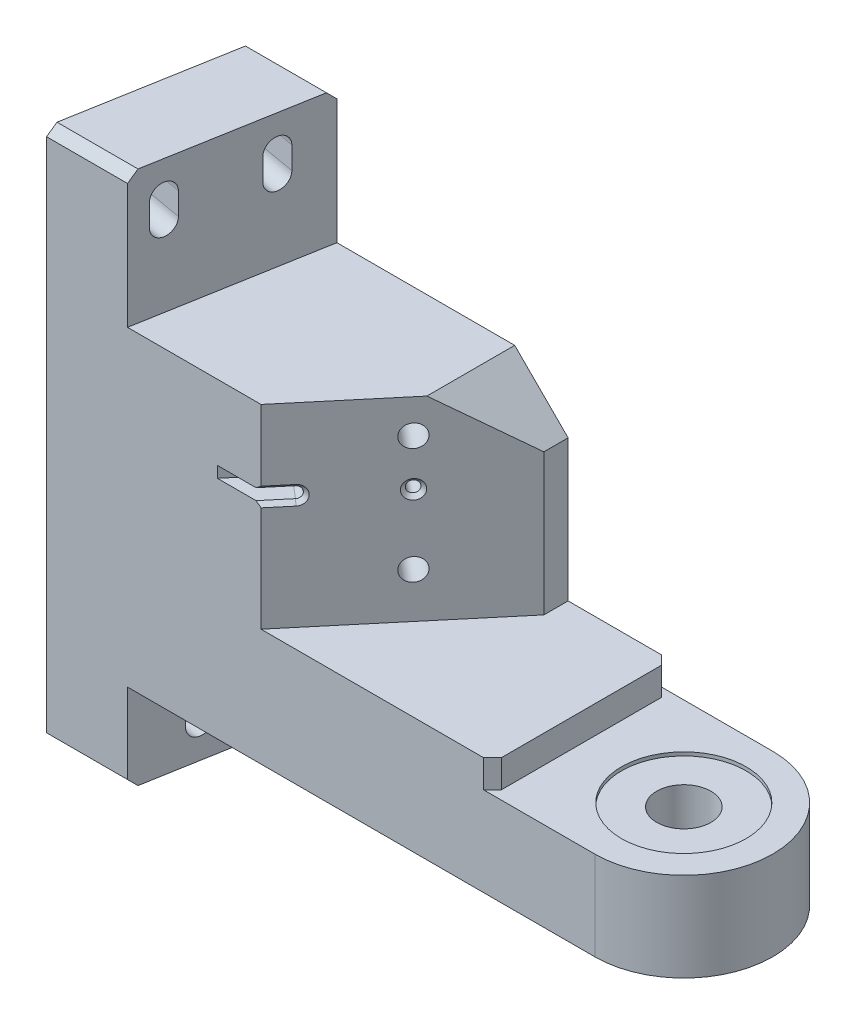
from build123d import *

# Parameters (mm, degrees)
SKETCH1_W                              = 181.864
SKETCH1_H                              = 50.8
EXTRUDE1_DEPTH                         = 152.4
EXTRUDE2_DEPTH                         = 153.4
EXTRUDE3_DEPTH                         = 38.1
EXTRUDE4_DEPTH                         = 55.5498
SKETCH5_W                              = 54.61
SKETCH5_H                              = 50.8
EXTRUDE5_DEPTH                         = 7.9502
EXTRUDE6_DEPTH                         = 25.4
EXTRUDE7_DEPTH                         = 32.584173829
LPATTERN1_COUNT                        = 2
LPATTERN1_PITCH                        = 127
LPATTERN1_COUNT_DIR2                   = 2
LPATTERN1_PITCH_DIR2                   = 27.94
F_1_4_20_TAPPED_HOLE1_D                = 5.1054
F_1_4_20_TAPPED_HOLE1_DEPTH            = 16.51
F_1_4_20_TAPPED_HOLE1_CBORE_D          = 6.35
F_1_4_20_TAPPED_HOLE1_CBORE_DEPTH      = 12.7
F_1_4_20_TAPPED_HOLE1_TIP              = 1.533816902
EXTRUDE9_DEPTH                         = 128
CHAMFER1_SIZE                          = 2.54
CHAMFER2_SIZE                          = 15.24
EXTRUDE10_DEPTH                        = 32.584173829
SCREW_THRU_HOLE_AND_CBORE_D            = 15.4686
SCREW_THRU_HOLE_AND_CBORE_CBORE_D      = 35.56
SCREW_THRU_HOLE_AND_CBORE_CBORE_DEPTH  = 1.016
F_1_8_0_125_DIAMETER_HOLE1_D           = 3.19024
F_1_8_0_125_DIAMETER_HOLE1_DEPTH       = 9.525
F_1_8_0_125_DIAMETER_HOLE1_CSINK_D     = 5.334
F_1_8_0_125_DIAMETER_HOLE1_CSINK_ANGLE = 90
F_1_8_0_125_DIAMETER_HOLE1_TIP         = 0.958444791
CUT_EXTRUDE1_DEPTH                     = 9.525
CHAMFER3_SIZE                          = 1.0795


with BuildPart() as part:
    # Sketch1 → Extrude1 (new body)
    with BuildSketch(Plane(origin=(0, 0, 0), x_dir=(1, 0, 0), z_dir=(0, 1, 0))):
        with Locations((-65.532, 0)):
            Rectangle(SKETCH1_W, SKETCH1_H)
    extrude(amount=EXTRUDE1_DEPTH)

    # Sketch2 → Extrude2 (cut, through all)
    with BuildSketch(Plane(origin=(0, 152.4, 0), x_dir=(1, 0, 0), z_dir=(0, 1, 0))):
        Polygon((-156.464, -25.4), (-156.464, 25.4), (-147.50658938, 25.4), align=None)
    extrude(amount=-EXTRUDE2_DEPTH, mode=Mode.SUBTRACT)

    # Sketch3 → Extrude3 (cut)
    with BuildSketch(Plane(origin=(0, 152.4, 0), x_dir=(1, 0, 0), z_dir=(0, 1, 0))):
        Polygon((25.4, -25.4), (25.4, 25.4), (-124.39258938, 25.4), (-133.35, -25.4), align=None)
    extrude(amount=-EXTRUDE3_DEPTH, mode=Mode.SUBTRACT)

    # Sketch4 → Extrude4 (cut)
    with BuildSketch(Plane(origin=(0, 114.3, 0), x_dir=(1, 0, 0), z_dir=(0, 1, 0))):
        Polygon((25.4, -25.4), (-95.25, -25.4), (-58.42, 18.492284815), (-58.42, 25.4), (25.4, 25.4), align=None)
    extrude(amount=-EXTRUDE4_DEPTH, mode=Mode.SUBTRACT)

    # Sketch5 → Extrude5 (cut)
    with BuildSketch(Plane(origin=(0, 58.7502, 0), x_dir=(1, 0, 0), z_dir=(0, 1, 0))):
        with Locations((-1.905, 0)):
            Rectangle(SKETCH5_W, SKETCH5_H)
    extrude(amount=-EXTRUDE5_DEPTH, mode=Mode.SUBTRACT)

    # Sketch6 → Extrude6 (cut)
    with BuildSketch(Plane.XZ):
        Polygon((25.4, 25.4), (25.4, -25.4), (-124.39258938, -25.4), (-133.35, 25.4), align=None)
    extrude(amount=-EXTRUDE6_DEPTH, mode=Mode.SUBTRACT)

    # Sketch7 → Extrude7 (cut, through all)
    with BuildSketch(Plane(origin=(-124.985349671, 0, -22.03828934), x_dir=(0.173648178, 0, -0.984807753), z_dir=(0.984807753, 0, 0.173648178))):
        with BuildLine():
            Line((-35.635705397, 142.9766), (-35.635705397, 136.6266))
            ThreePointArc((-35.635705397, 136.6266), (-39.204405397, 133.0579), (-42.773105397, 136.6266))
            Line((-42.773105397, 136.6266), (-42.773105397, 142.9766))
            ThreePointArc((-42.773105397, 142.9766), (-39.204405397, 146.5453), (-35.635705397, 142.9766))
        make_face()
    extrude7 = extrude(amount=-EXTRUDE7_DEPTH, mode=Mode.SUBTRACT)

    # LPattern1: Extrude7 2 × 2, 1 skipped
    with Locations(*[Vector(0, -1, 0) * (i * LPATTERN1_PITCH) + Vector(0.173648178, 0, -0.984807753) * (j * LPATTERN1_PITCH_DIR2) for i in range(LPATTERN1_COUNT) for j in range(LPATTERN1_COUNT_DIR2) if (i, j) not in ((0, 0), (1, 0))]):
        add(extrude7, mode=Mode.SUBTRACT)

    # 1/4-20 Tapped Hole1
    with Locations(Plane(origin=(-43.387935998, 0, -36.406801094), x_dir=(0.64278761, 0, -0.766044443), z_dir=(0.766044443, 0, 0.64278761))):
        with Locations((-49.822048678, 104.648), (-49.822048678, 71.628)):
            CounterBoreHole(F_1_4_20_TAPPED_HOLE1_D / 2, F_1_4_20_TAPPED_HOLE1_CBORE_D / 2, F_1_4_20_TAPPED_HOLE1_CBORE_DEPTH, depth=F_1_4_20_TAPPED_HOLE1_DEPTH)
            with Locations((0, 0, -(F_1_4_20_TAPPED_HOLE1_DEPTH + F_1_4_20_TAPPED_HOLE1_TIP / 2))):  # 118° drill point
                Cone(0, F_1_4_20_TAPPED_HOLE1_D / 2, F_1_4_20_TAPPED_HOLE1_TIP, mode=Mode.SUBTRACT)

    # Sketch19 → Extrude9 (cut, through all)
    with BuildSketch(Plane.XZ.offset(-25.4)):
        with BuildLine():
            Line((27.94, 25.4), (0, 25.4))
            ThreePointArc((0, 25.4), (25.4, 0), (0, -25.4))
            Line((0, -25.4), (27.94, -25.4))
            Line((27.94, -25.4), (27.94, 25.4))
        make_face()
    extrude(amount=-EXTRUDE9_DEPTH, mode=Mode.SUBTRACT)

    # Chamfer1
    chamfer1_edges = [part.edges().sort_by_distance(p)[0] for p in [
        (-135.94958938, 152.4, -25.4),
        (-144.907, 0, 25.4),
        (-29.21, 54.7751, 25.4),
        (-29.21, 54.7751, -25.4),
        (-135.94958938, 0, -25.4),
        (-144.907, 152.4, 25.4),
    ]]
    chamfer(chamfer1_edges, length=CHAMFER1_SIZE)

    # Chamfer2
    chamfer2_edges = [part.edges().sort_by_distance(p)[0] for p in [
        (-58.42, 114.3, -21.946142408),
    ]]
    chamfer(chamfer2_edges, length=CHAMFER2_SIZE)

    # Sketch20 → Extrude10 (cut, through all)
    with BuildSketch(Plane(origin=(-124.985349671, 0, -22.03828934), x_dir=(0.173648178, 0, -0.984807753), z_dir=(0.984807753, 0, 0.173648178))):
        with BuildLine():
            Line((-26.745705397, 15.9766), (-26.745705397, 9.6266))
            ThreePointArc((-26.745705397, 9.6266), (-30.314405397, 6.0579), (-33.883105397, 9.6266))
            Line((-33.883105397, 9.6266), (-33.883105397, 15.9766))
            ThreePointArc((-33.883105397, 15.9766), (-30.314405397, 19.5453), (-26.745705397, 15.9766))
        make_face()
    extrude(amount=-EXTRUDE10_DEPTH, mode=Mode.SUBTRACT)

    # SCREW THRU HOLE AND CBORE (through all)
    with Locations(Plane(origin=(0, 50.8, 0), x_dir=(-1, 0, 0), z_dir=(0, 1, 0))):
        with Locations((0, 0)):
            CounterBoreHole(SCREW_THRU_HOLE_AND_CBORE_D / 2, SCREW_THRU_HOLE_AND_CBORE_CBORE_D / 2, SCREW_THRU_HOLE_AND_CBORE_CBORE_DEPTH)

    # 1/8 (0.125) Diameter Hole1
    with Locations(Plane(origin=(-43.387935998, 0, -36.406801094), x_dir=(0.64278761, 0, -0.766044443), z_dir=(0.766044443, 0, 0.64278761))):
        with Locations((-49.784, 91.412613047)):
            CounterSinkHole(F_1_8_0_125_DIAMETER_HOLE1_D / 2, F_1_8_0_125_DIAMETER_HOLE1_CSINK_D / 2, depth=F_1_8_0_125_DIAMETER_HOLE1_DEPTH, counter_sink_angle=F_1_8_0_125_DIAMETER_HOLE1_CSINK_ANGLE)
            with Locations((0, 0, -(F_1_8_0_125_DIAMETER_HOLE1_DEPTH + F_1_8_0_125_DIAMETER_HOLE1_TIP / 2))):  # 118° drill point
                Cone(0, F_1_8_0_125_DIAMETER_HOLE1_D / 2, F_1_8_0_125_DIAMETER_HOLE1_TIP, mode=Mode.SUBTRACT)

    # Sketch26 → Cut-Extrude1 (cut)
    with BuildSketch(Plane(origin=(-43.387935998, 0, -36.406801094), x_dir=(0.64278761, 0, -0.766044443), z_dir=(0.766044443, 0, 0.64278761))):
        with BuildLine():
            Line((-73.6092, 89.817493047), (-92.6592, 89.817493047))
            ThreePointArc((-92.6592, 89.817493047), (-94.25432, 91.412613047), (-92.6592, 93.007733047))
            Line((-92.6592, 93.007733047), (-73.6092, 93.007733047))
            ThreePointArc((-73.6092, 93.007733047), (-72.01408, 91.412613047), (-73.6092, 89.817493047))
        make_face()
    extrude(amount=-CUT_EXTRUDE1_DEPTH, mode=Mode.SUBTRACT)

    # Chamfer3
    chamfer3_edges = [part.edges().sort_by_distance(p)[0] for p in [
        (-92.976508859, 89.817493047, 22.690558764),
        (-92.976508859, 93.007733047, 22.690558764),
        (-89.677694345, 91.412613047, 18.759184717),
    ]]
    chamfer(chamfer3_edges, length=CHAMFER3_SIZE)


solid = part.part
